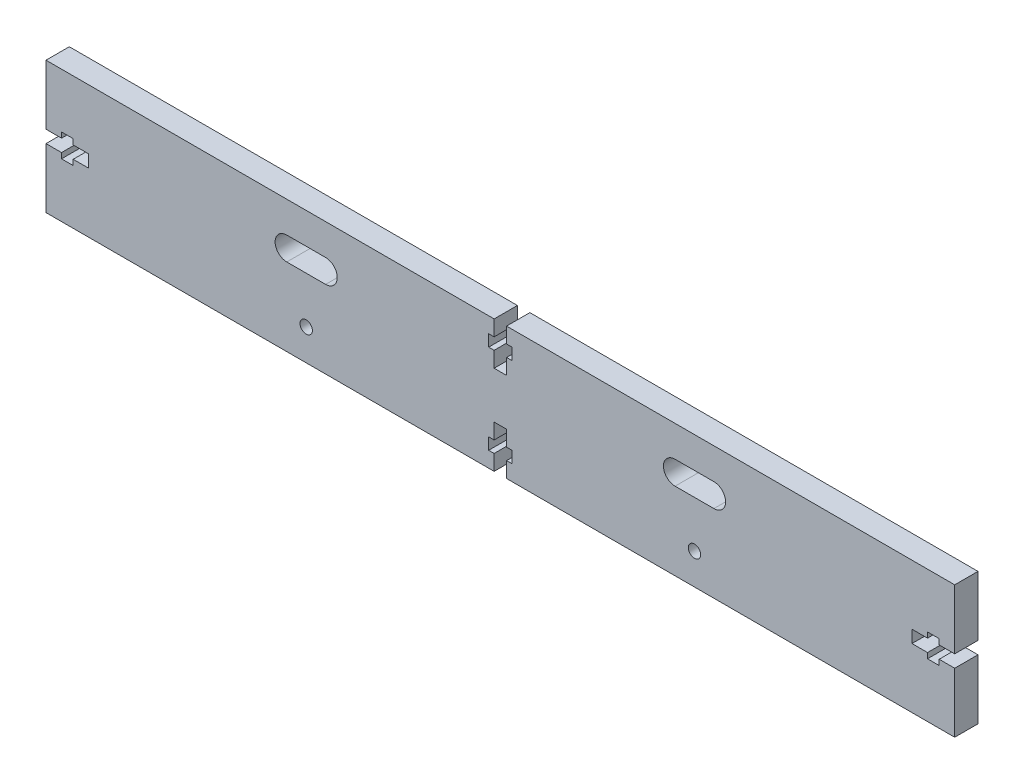
from build123d import *

# Parameters (mm, degrees)
ESBO_O1_R                = 1.6
RESSALTO_EXTRUS_O1_DEPTH = 6


with BuildPart() as part:
    # Esboço1 → Ressalto-extrusão1 (new body)
    with BuildSketch(Plane.XY):
        Polygon((117, 17), (117, 1.6), (113, 1.6), (113, 3), (110, 3), (110, 1.6), (106, 1.6), (106, -1.6), (110, -1.6), (110, -3), (113, -3), (113, -1.6), (117, -1.6), (117, -17), (1.6, -17), (1.6, -13), (3, -13), (3, -10), (1.6, -10), (1.6, -6), (-1.6, -6), (-1.6, -10), (-3, -10), (-3, -13), (-1.6, -13), (-1.6, -17), (-117, -17), (-117, -1.6), (-113, -1.6), (-113, -3), (-110, -3), (-110, -1.6), (-106, -1.6), (-106, 1.6), (-110, 1.6), (-110, 3), (-113, 3), (-113, 1.6), (-117, 1.6), (-117, 17), (-1.6, 17), (-1.6, 13), (-3, 13), (-3, 10), (-1.6, 10), (-1.6, 6), (1.6, 6), (1.6, 10), (3, 10), (3, 13), (1.6, 13), (1.6, 17), align=None)
        with Locations((-50, -9)):
            Circle(ESBO_O1_R, mode=Mode.SUBTRACT)
        with Locations((50, -9)):
            Circle(ESBO_O1_R, mode=Mode.SUBTRACT)
        with BuildLine():
            Line((-55, 9), (-45, 9))
            ThreePointArc((-45, 9), (-42, 6), (-45, 3))
            Line((-45, 3), (-55, 3))
            ThreePointArc((-55, 3), (-58, 6), (-55, 9))
        make_face(mode=Mode.SUBTRACT)
        with BuildLine():
            Line((55, 9), (45, 9))
            ThreePointArc((45, 9), (42, 6), (45, 3))
            Line((45, 3), (55, 3))
            ThreePointArc((55, 3), (58, 6), (55, 9))
        make_face(mode=Mode.SUBTRACT)
    extrude(amount=RESSALTO_EXTRUS_O1_DEPTH)


solid = part.part
